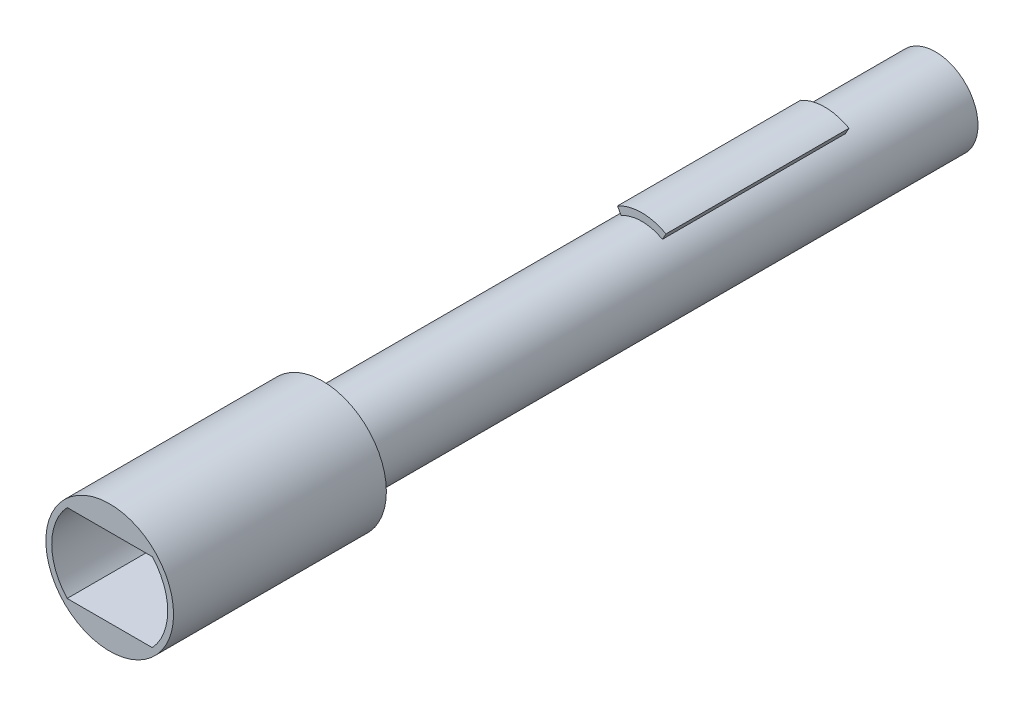
from build123d import *

# Parameters (mm, degrees)
SKETCH3_R           = 2
BOSS_EXTRUDE1_DEPTH = 5.2
SKETCH4_R           = 2
BOSS_EXTRUDE2_DEPTH = 8.6
SKETCH5_R           = 2
BOSS_EXTRUDE3_DEPTH = 15
SKETCH6_R           = 3
BOSS_EXTRUDE4_DEPTH = 10
CUT_EXTRUDE1_DEPTH  = 8


with BuildPart() as part:
    # Sketch3 → Boss-Extrude1 (new body)
    with BuildSketch(Plane.XY):
        Circle(SKETCH3_R)
    extrude(amount=BOSS_EXTRUDE1_DEPTH)

    # Sketch4 → Boss-Extrude2 (add)
    with BuildSketch(Plane.XY.offset(5.2)):
        with Locations(Location((0, 0, 0), (0, 0, 119))):
            Circle(SKETCH4_R)
        with BuildLine():
            Line((0, 0), (1.139302608, 2.055356312))
            ThreePointArc((1.139302608, 2.055356312), (0, 2.35), (-1.139302608, 2.055356312))
            Line((-1.139302608, 2.055356312), (0, 0))
        make_face()
        with BuildLine():
            Line((0.96961924, 1.749239414), (0, 0))
            Line((0, 0), (-0.96961924, 1.749239414))
            ThreePointArc((-0.96961924, 1.749239414), (-1.015076726, -1.723258321), (2, 0))
            ThreePointArc((2, 0), (1.723258321, 1.015076726), (0.96961924, 1.749239414))
        make_face()
    extrude(amount=BOSS_EXTRUDE2_DEPTH)

    # Sketch5 → Boss-Extrude3 (add)
    with BuildSketch(Plane.XY.offset(13.8)):
        Circle(SKETCH5_R)
    extrude(amount=BOSS_EXTRUDE3_DEPTH)

    # Sketch6 → Boss-Extrude4 (add)
    with BuildSketch(Plane.XY.offset(28.8)):
        Circle(SKETCH6_R)
    extrude(amount=BOSS_EXTRUDE4_DEPTH)

    # Sketch7 → Cut-Extrude1 (cut)
    with BuildSketch(Plane.XY.offset(38.8)):
        with BuildLine():
            Line((2.000781097, 1.85), (-2.000781097, 1.85))
            ThreePointArc((-2.000781097, 1.85), (-2.725, 0), (-2.000781097, -1.85))
            Line((-2.000781097, -1.85), (2.000781097, -1.85))
            ThreePointArc((2.000781097, -1.85), (2.725, 0), (2.000781097, 1.85))
        make_face()
    extrude(amount=-CUT_EXTRUDE1_DEPTH, mode=Mode.SUBTRACT)


solid = part.part
